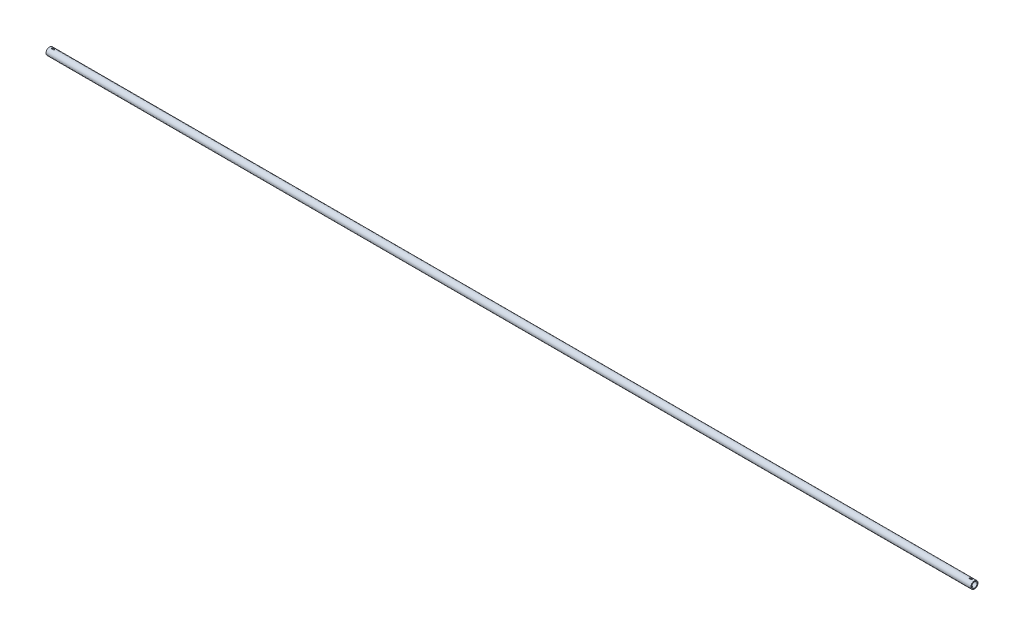
from build123d import *

# Parameters (mm, degrees)
SKETCH_1_R               = 20
SKETCH_1_R_2             = 14
EXTRUDE_1_DEPTH          = 5145
SKETCH_2_R               = 15
CUT_EXTRUDE_1_DEPTH      = 70
SKETCH_3_R               = 15
CUT_EXTRUDE_2_DEPTH      = 70
CUT_EXTRUDE_3_DEPTH      = 21
CUT_EXTRUDE_3_DEPTH_BACK = 21


with BuildPart() as part:
    # 草图1 → 凸台-拉伸1 (new body)
    with BuildSketch(Plane(origin=(0, 0, 0), x_dir=(0, 0, -1), z_dir=(1, 0, 0))):
        Circle(SKETCH_1_R)
        Circle(SKETCH_1_R_2, mode=Mode.SUBTRACT)
    extrude(amount=EXTRUDE_1_DEPTH)

    # 草图2 → 切除-拉伸1 (cut)
    with BuildSketch(Plane.ZY):
        Circle(SKETCH_2_R)
    extrude(amount=-CUT_EXTRUDE_1_DEPTH, mode=Mode.SUBTRACT)

    # 草图3 → 切除-拉伸2 (cut)
    with BuildSketch(Plane(origin=(5145, 0, 0), x_dir=(0, 0, -1), z_dir=(1, 0, 0))):
        Circle(SKETCH_3_R)
    extrude(amount=-CUT_EXTRUDE_2_DEPTH, mode=Mode.SUBTRACT)

    # 草图4 → 切除-拉伸3 (cut, two sides)
    with BuildSketch(Plane(origin=(0, 0, 0), x_dir=(1, 0, 0), z_dir=(0, 1, 0))) as cut_extrude_3_sk:
        with BuildLine():
            Line((5120, 3), (5130, 3))
            ThreePointArc((5130, 3), (5133, 0), (5130, -3))
            Line((5130, -3), (5120, -3))
            ThreePointArc((5120, -3), (5117, 0), (5120, 3))
        make_face()
        with BuildLine():
            Line((15, 3), (25, 3))
            ThreePointArc((25, 3), (28, 0), (25, -3))
            Line((25, -3), (15, -3))
            ThreePointArc((15, -3), (12, 0), (15, 3))
        make_face()
    extrude(amount=CUT_EXTRUDE_3_DEPTH, mode=Mode.SUBTRACT)
    extrude(cut_extrude_3_sk.sketch, amount=-CUT_EXTRUDE_3_DEPTH_BACK, mode=Mode.SUBTRACT)


solid = part.part
